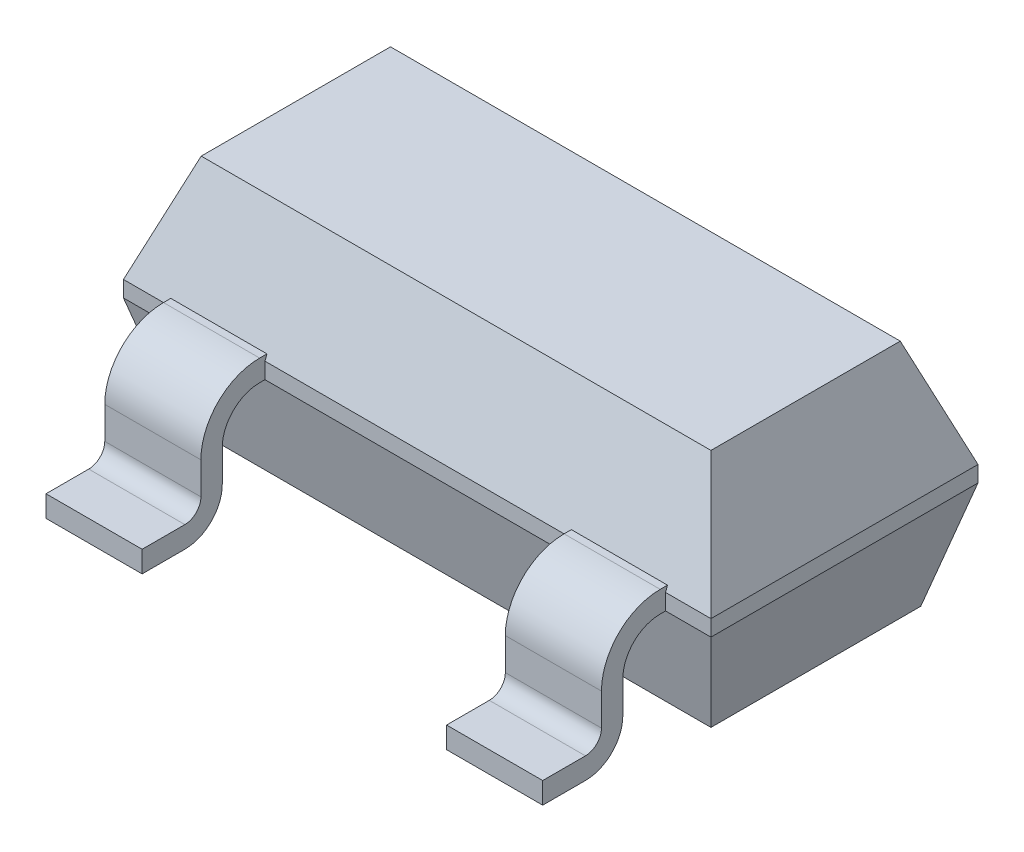
from build123d import *

# Parameters (mm, degrees)
SKETCH2_W                = 2.794
SKETCH2_H                = 1.27
BASE_EXTRUDE_DEPTH       = 1.0922
CHAMFER1_SIZE2           = 0.184896879
CHAMFER1_SIZE            = 0.508
CHAMFER2_SIZE2           = 0.508
CHAMFER2_SIZE            = 0.13611819
CHAMFER2_EDGE_2_SIZE2    = 0.508
CHAMFER2_EDGE_2_SIZE     = 0.13611819
CHAMFER2_EDGE_3_SIZE2    = 0.508
CHAMFER2_EDGE_3_SIZE     = 0.13611819
CHAMFER2_EDGE_4_SIZE2    = 0.508
CHAMFER2_EDGE_4_SIZE     = 0.13611819
BOSS_EXTRUDE_THIN2_DEPTH = 0.2286
LPATTERN1_COUNT          = 2
LPATTERN1_PITCH          = 1.905
BOSS_EXTRUDE_THIN3_DEPTH = 0.2286


with BuildPart() as part:
    # Sketch2 → Base-Extrude (new body)
    with BuildSketch(Plane(origin=(0, 0, 0), x_dir=(1, 0, 0), z_dir=(0, 1, 0))):
        with Locations((0.9525, 0.9525)):
            Rectangle(SKETCH2_W, SKETCH2_H)
    extrude(amount=BASE_EXTRUDE_DEPTH)

    # Chamfer1
    chamfer1_edges = [part.edges().sort_by_distance(p)[0] for p in [
        (2.3495, 1.0922, -0.9525),
        (0.9525, 1.0922, -1.5875),
        (-0.4445, 1.0922, -0.9525),
        (0.9525, 1.0922, -0.3175),
    ]]
    chamfer(chamfer1_edges, length=CHAMFER1_SIZE, length2=CHAMFER1_SIZE2)

    # Chamfer2
    chamfer2_edges = [part.edges().sort_by_distance(p)[0] for p in [
        (0.9525, 0, -1.5875),
    ]]
    chamfer(chamfer2_edges, length=CHAMFER2_SIZE, length2=CHAMFER2_SIZE2)

    # Chamfer2 edge 2
    chamfer2_edge_2_edges = [part.edges().sort_by_distance(p)[0] for p in [
        (2.3495, 0, -0.9525),
    ]]
    chamfer(chamfer2_edge_2_edges, length=CHAMFER2_EDGE_2_SIZE, length2=CHAMFER2_EDGE_2_SIZE2)

    # Chamfer2 edge 3
    chamfer2_edge_3_edges = [part.edges().sort_by_distance(p)[0] for p in [
        (0.9525, 0, -0.3175),
    ]]
    chamfer(chamfer2_edge_3_edges, length=CHAMFER2_EDGE_3_SIZE, length2=CHAMFER2_EDGE_3_SIZE2)

    # Chamfer2 edge 4
    chamfer2_edge_4_edges = [part.edges().sort_by_distance(p)[0] for p in [
        (-0.4445, 0, -0.9525),
    ]]
    chamfer(chamfer2_edge_4_edges, length=CHAMFER2_EDGE_4_SIZE, length2=CHAMFER2_EDGE_4_SIZE2)

    # Sketch3 → Boss-Extrude-Thin2 (add, symmetric)
    with BuildSketch(Plane(origin=(0, 0, 0), x_dir=(0, 0, -1), z_dir=(1, 0, 0))):
        with BuildLine():
            Line((0.640403251, 0.508), (0.2921, 0.508))
            ThreePointArc((0.2921, 0.508), (0.166376414, 0.455923586), (0.1143, 0.3302))
            Line((0.1143, 0.3302), (0.1143, 0.1778))
            ThreePointArc((0.1143, 0.1778), (0.062223586, 0.052076414), (-0.0635, 0))
            Line((-0.0635, 0), (-0.2667, 0))
            Line((-0.2667, 0), (-0.2667, 0.1016))
            Line((-0.2667, 0.1016), (-0.0635, 0.1016))
            ThreePointArc((-0.0635, 0.1016), (-0.009618463, 0.123918463), (0.0127, 0.1778))
            Line((0.0127, 0.1778), (0.0127, 0.3302))
            ThreePointArc((0.0127, 0.3302), (0.094534365, 0.527765635), (0.2921, 0.6096))
            Line((0.2921, 0.6096), (0.640403251, 0.6096))
            Line((0.640403251, 0.6096), (0.640403251, 0.508))
        make_face()
    boss_extrude_thin2 = extrude(amount=BOSS_EXTRUDE_THIN2_DEPTH, both=True)

    # LPattern1: Boss-Extrude-Thin2 ×2
    with Locations(*[(i * LPATTERN1_PITCH, 0, 0) for i in range(1, LPATTERN1_COUNT)]):
        add(boss_extrude_thin2)

    # Sketch4 → Boss-Extrude-Thin3 (add, symmetric)
    with BuildSketch(Plane(origin=(0.9525, 0, 0), x_dir=(0, 0, -1), z_dir=(1, 0, 0))):
        with BuildLine():
            Line((2.1717, 0), (1.9685, 0))
            ThreePointArc((1.9685, 0), (1.842776414, 0.052076414), (1.7907, 0.1778))
            Line((1.7907, 0.1778), (1.7907, 0.3302))
            ThreePointArc((1.7907, 0.3302), (1.738623586, 0.455923586), (1.6129, 0.508))
            Line((1.6129, 0.508), (1.323627418, 0.508))
            Line((1.323627418, 0.508), (1.323627418, 0.6096))
            Line((1.323627418, 0.6096), (1.6129, 0.6096))
            ThreePointArc((1.6129, 0.6096), (1.810465635, 0.527765635), (1.8923, 0.3302))
            Line((1.8923, 0.3302), (1.8923, 0.1778))
            ThreePointArc((1.8923, 0.1778), (1.914618463, 0.123918463), (1.9685, 0.1016))
            Line((1.9685, 0.1016), (2.1717, 0.1016))
            Line((2.1717, 0.1016), (2.1717, 0))
        make_face()
    extrude(amount=BOSS_EXTRUDE_THIN3_DEPTH, both=True)


solid = part.part
